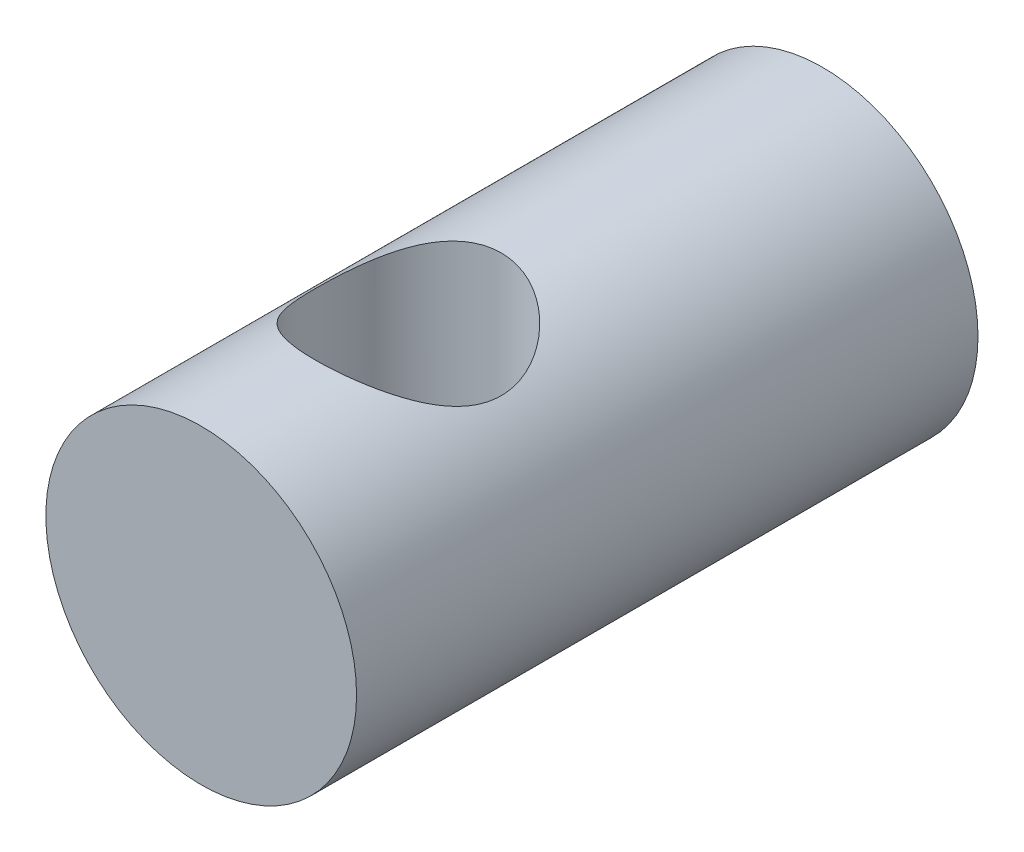
from build123d import *

# Parameters (mm, degrees)
SKETCH1_R              = 3.175
BOSS_EXTRUDE1_DEPTH    = 12.7
F_10_24_TAPPED_HOLE2_D = 3.7973


with BuildPart() as part:
    # Sketch1 → Boss-Extrude1 (new body)
    with BuildSketch(Plane.XY):
        Circle(SKETCH1_R)
    extrude(amount=BOSS_EXTRUDE1_DEPTH)

    # #10-24 Tapped Hole2 (through all)
    with Locations(Plane(origin=(0, 3.175, 8.466666582), x_dir=(1, 0, 0), z_dir=(0, 1, 0))):
        with Locations((0, 0)):
            Hole(F_10_24_TAPPED_HOLE2_D / 2)


solid = part.part
